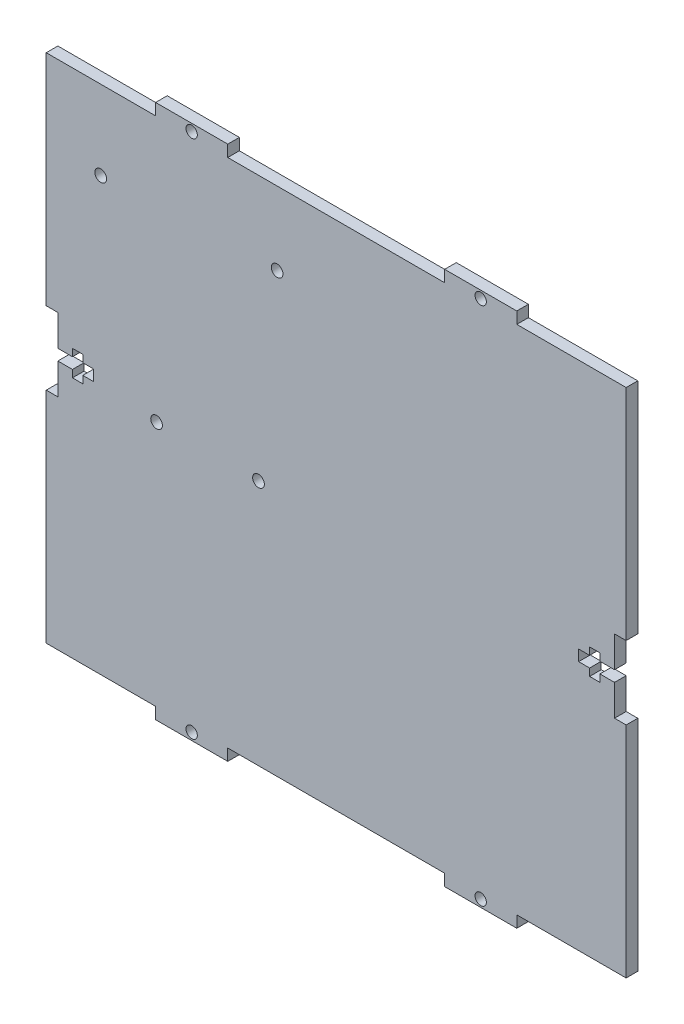
from build123d import *

# Parameters (mm, degrees)
SKETCH1_W               = 158.76
SKETCH1_H               = 146.36
BOSS_EXTRUDE1_DEPTH     = 3.18
CUT_EXTRUDE1_START      = -4.18
SKETCH2_W               = 29.94
SKETCH2_H               = 3.18
SKETCH2_W_2             = 59.38
CUT_EXTRUDE1_DEPTH      = 5.18
CUT_EXTRUDE2_START      = -4.18
SKETCH3_R               = 1.55
CUT_EXTRUDE2_DEPTH      = 5.18
MIRROR3_START           = -4.18
MIRROR3_COPY_1_SKETCH_R = 1.55
MIRROR3_COPY_1_DEPTH    = 5.18
CUT_EXTRUDE3_START      = -4.18
SKETCH5_W               = 3.18
SKETCH5_H               = 20
SKETCH5_W_2             = 2.82
SKETCH5_H_2             = 7
SKETCH5_W_3             = 13
SKETCH5_H_3             = 3
CUT_EXTRUDE3_DEPTH      = 5.18
SKETCH7_R               = 1.6
CUT_EXTRUDE4_DEPTH      = 1
CUT_EXTRUDE4_DEPTH_BACK = 4.18


with BuildPart() as part:
    # Sketch1 → Boss-Extrude1 (new body)
    with BuildSketch(Plane.XY):
        Rectangle(SKETCH1_W, SKETCH1_H)
    extrude(amount=BOSS_EXTRUDE1_DEPTH)

    # Sketch2 → Cut-Extrude1 (cut)
    with BuildSketch(Plane.XY.offset(3.18).offset(CUT_EXTRUDE1_START)):
        with Locations((-64.41, 71.59)):
            Rectangle(SKETCH2_W, SKETCH2_H)
        with Locations((0, 71.59)):
            Rectangle(SKETCH2_W_2, SKETCH2_H)
        with Locations((64.41, 71.59)):
            Rectangle(SKETCH2_W, SKETCH2_H)
    cut_extrude1 = extrude(amount=CUT_EXTRUDE1_DEPTH, mode=Mode.SUBTRACT)

    # Mirror1: Cut-Extrude1 across plane
    add(cut_extrude1.mirror(Plane.ZX), mode=Mode.SUBTRACT)

    # Sketch3 → Cut-Extrude2 (cut)
    with BuildSketch(Plane.XY.offset(3.18).offset(CUT_EXTRUDE2_START)):
        with Locations((-39.565, -71.18)):
            Circle(SKETCH3_R)
    cut_extrude2 = extrude(amount=CUT_EXTRUDE2_DEPTH, mode=Mode.SUBTRACT)

    # Mirror2: Cut-Extrude2 across plane
    add(cut_extrude2.mirror(Plane(origin=(0, 0, 0), x_dir=(0, 0, 1), z_dir=(1, 0, 0))), mode=Mode.SUBTRACT)

    # Mirror3: Cut-Extrude2 across plane
    add(cut_extrude2.mirror(Plane.ZX), mode=Mode.SUBTRACT)

    # Mirror3 copy 1 sketch → Mirror3 copy 1 (cut)
    with BuildSketch(Plane(origin=(0, 0, 3.18), x_dir=(-1, 0, 0), z_dir=(0, 0, 1)).offset(MIRROR3_START)):
        with Locations((-39.565, -71.18)):
            Circle(MIRROR3_COPY_1_SKETCH_R)
    extrude(amount=MIRROR3_COPY_1_DEPTH, mode=Mode.SUBTRACT)

    # Sketch5 → Cut-Extrude3 (cut)
    with BuildSketch(Plane(origin=(0, 0, 0), x_dir=(-1, 0, 0), z_dir=(0, 0, -1)).offset(CUT_EXTRUDE3_START)):
        with Locations((-77.79, 0)):
            Rectangle(SKETCH5_W, SKETCH5_H)
        with Locations((-70.79, 0)):
            Rectangle(SKETCH5_W_2, SKETCH5_H_2)
        with Locations((-72.88, 0)):
            Rectangle(SKETCH5_W_3, SKETCH5_H_3)
    cut_extrude3 = extrude(amount=CUT_EXTRUDE3_DEPTH, mode=Mode.SUBTRACT)

    # Mirror4: Cut-Extrude3 across plane
    add(cut_extrude3.mirror(Plane(origin=(0, 0, 0), x_dir=(0, 0, 1), z_dir=(1, 0, 0))), mode=Mode.SUBTRACT)

    # Sketch7 → Cut-Extrude4 (cut, two sides)
    with BuildSketch(Plane(origin=(0, 0, 0), x_dir=(-1, 0, 0), z_dir=(0, 0, -1))) as cut_extrude4_sk:
        with Locations((64.474463585, 48.325)):
            Circle(SKETCH7_R)
        with Locations((16.174463585, 49.925)):
            Circle(SKETCH7_R)
        with Locations((49.174463585, -2.475)):
            Circle(SKETCH7_R)
        with Locations((21.274463585, -2.475)):
            Circle(SKETCH7_R)
    extrude(amount=CUT_EXTRUDE4_DEPTH, mode=Mode.SUBTRACT)
    extrude(cut_extrude4_sk.sketch, amount=-CUT_EXTRUDE4_DEPTH_BACK, mode=Mode.SUBTRACT)


solid = part.part
